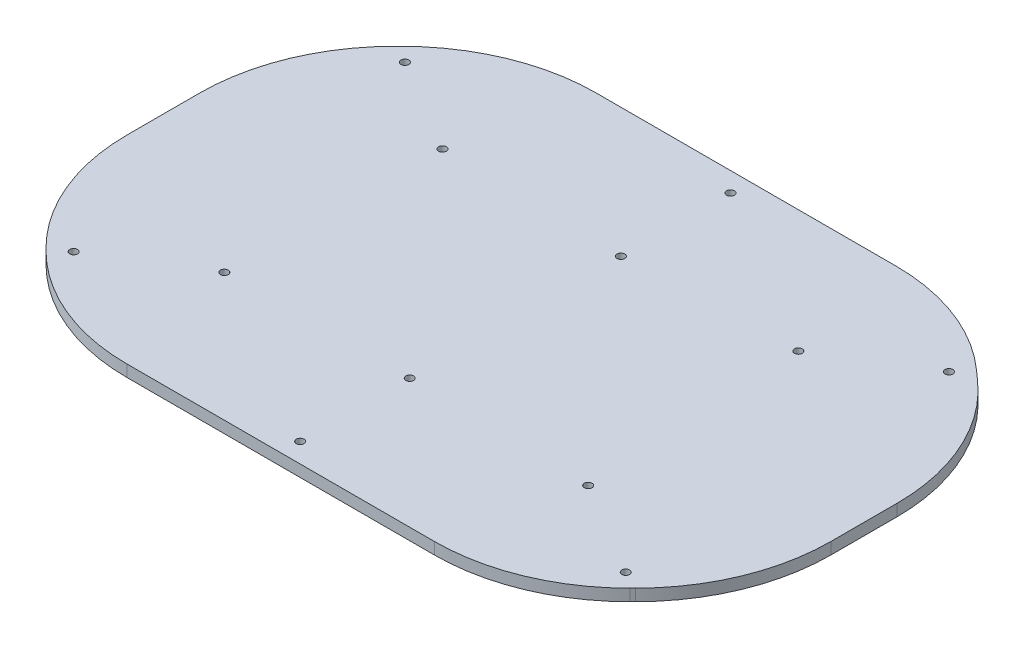
from build123d import *

# Parameters (mm, degrees)
BOSS_EXTRUDE1_DEPTH = 3
SKETCH3_R           = 1
CUT_EXTRUDE1_DEPTH  = 4


with BuildPart() as part:
    # Sketch1 → Boss-Extrude1 (new body)
    with BuildSketch(Plane(origin=(0, 0, 0), x_dir=(1, 0, 0), z_dir=(0, 1, 0))):
        with BuildLine():
            Line((27.034499206, -59.38314523), (27.034499206, -77.961788992))
            ThreePointArc((27.034499206, -77.961788992), (30.840522581, -97.095960611), (41.679160147, -113.317128052))
            Line((41.679160147, -113.317128052), (42.389838265, -114.02780617))
            ThreePointArc((42.389838265, -114.02780617), (58.611005706, -124.866443737), (77.745177325, -128.672467111))
            Line((77.745177325, -128.672467111), (156.323821087, -128.672467111))
            ThreePointArc((156.323821087, -128.672467111), (175.457992706, -124.866443737), (191.679160147, -114.02780617))
            Line((191.679160147, -114.02780617), (192.389838265, -113.317128052))
            ThreePointArc((192.389838265, -113.317128052), (203.228475832, -97.095960611), (207.034499206, -77.961788992))
            Line((207.034499206, -77.961788992), (207.034499206, -61.064291371))
            ThreePointArc((207.034499206, -61.064291371), (202.66744641, -40.628192686), (190.329134028, -23.761914877))
            Line((190.329134028, -23.761914877), (187.649401106, -21.370090617))
            ThreePointArc((187.649401106, -21.370090617), (172.171628737, -11.954596736), (154.354766284, -8.672467111))
            Line((154.354766284, -8.672467111), (77.745177325, -8.672467111))
            ThreePointArc((77.745177325, -8.672467111), (58.611005706, -12.478490485), (42.389838265, -23.317128052))
            Line((42.389838265, -23.317128052), (41.679160147, -24.02780617))
            ThreePointArc((41.679160147, -24.02780617), (30.840522581, -40.248973611), (27.034499206, -59.38314523))
        make_face()
    extrude(amount=BOSS_EXTRUDE1_DEPTH)

    # Sketch3 → Cut-Extrude1 (cut, through all)
    with BuildSketch(Plane(origin=(0, 3, 0), x_dir=(1, 0, 0), z_dir=(0, 1, 0))):
        with Locations((70.463718508, -40.729998692)):
            Circle(SKETCH3_R)
        with Locations((46.453916589, -26.324117541)):
            Circle(SKETCH3_R)
        with Locations((117.034499206, -41.672467111)):
            Circle(SKETCH3_R)
        with Locations((184.546793577, -25.302810972)):
            Circle(SKETCH3_R)
        with Locations((117.034499206, -13.672467111)):
            Circle(SKETCH3_R)
        with Locations((160.707496688, -39.989128545)):
            Circle(SKETCH3_R)
        with Locations((163.605279904, -96.61493553)):
            Circle(SKETCH3_R)
        with Locations((187.615081824, -111.020816682)):
            Circle(SKETCH3_R)
        with Locations((117.034499206, -95.672467111)):
            Circle(SKETCH3_R)
        with Locations((117.034499206, -123.672467111)):
            Circle(SKETCH3_R)
        with Locations((46.054672056, -110.621572149)):
            Circle(SKETCH3_R)
        with Locations((69.893968945, -95.935254577)):
            Circle(SKETCH3_R)
    extrude(amount=-CUT_EXTRUDE1_DEPTH, mode=Mode.SUBTRACT)


solid = part.part
